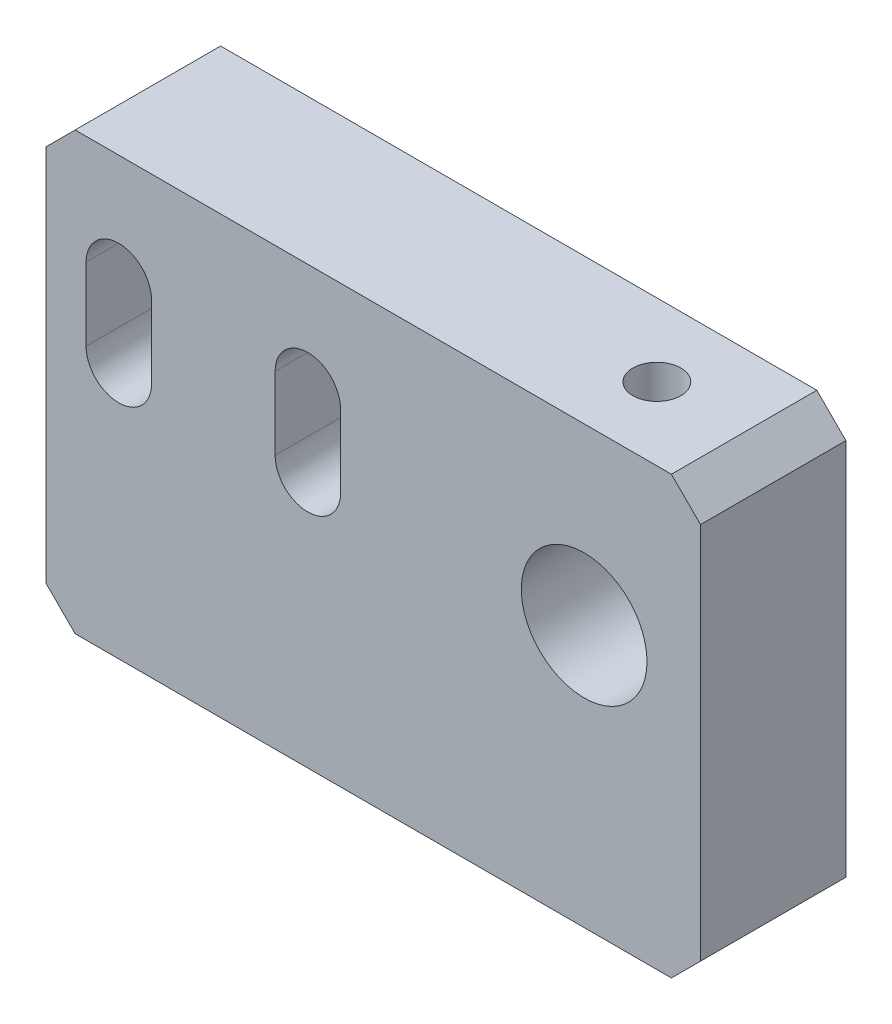
from build123d import *

# Parameters (mm, degrees)
SKETCH1_W             = 45
SKETCH1_H             = 30
SKETCH1_R             = 4.32205537
BOSS_EXTRUDE1_DEPTH   = 10
M4_TAPPED_HOLE1_D     = 3.3
M4_TAPPED_HOLE1_DEPTH = 10.1
M4_TAPPED_HOLE1_TIP   = 0.991420021
CHAMFER2_SIZE         = 2


with BuildPart() as part:
    # Sketch1 → Boss-Extrude1 (new body)
    with BuildSketch(Plane.XY):
        with Locations((7.992537313, -2.5)):
            Rectangle(SKETCH1_W, SKETCH1_H)
        with Locations((22.492537313, 0.5)):
            Circle(SKETCH1_R, mode=Mode.SUBTRACT)
        with BuildLine():
            Line((-7.257462687, 5), (-7.257462687, 0))
            ThreePointArc((-7.257462687, 0), (-9.507462687, -2.25), (-11.757462687, 0))
            Line((-11.757462687, 0), (-11.757462687, 5))
            ThreePointArc((-11.757462687, 5), (-9.507462687, 7.25), (-7.257462687, 5))
        make_face(mode=Mode.SUBTRACT)
        with BuildLine():
            Line((5.742537313, 5), (5.742537313, 0))
            ThreePointArc((5.742537313, 0), (3.492537313, -2.25), (1.242537313, 0))
            Line((1.242537313, 0), (1.242537313, 5))
            ThreePointArc((1.242537313, 5), (3.492537313, 7.25), (5.742537313, 5))
        make_face(mode=Mode.SUBTRACT)
    extrude(amount=BOSS_EXTRUDE1_DEPTH)

    # M4 Tapped Hole1
    with Locations(Plane(origin=(0, 12.5, 0), x_dir=(1, 0, 0), z_dir=(0, 1, 0))):
        with Locations((22.492537313, -5)):
            Hole(M4_TAPPED_HOLE1_D / 2, depth=M4_TAPPED_HOLE1_DEPTH)
            with Locations((0, 0, -(M4_TAPPED_HOLE1_DEPTH + M4_TAPPED_HOLE1_TIP / 2))):  # 118° drill point
                Cone(0, M4_TAPPED_HOLE1_D / 2, M4_TAPPED_HOLE1_TIP, mode=Mode.SUBTRACT)

    # Chamfer2
    chamfer2_edges = [part.edges().sort_by_distance(p)[0] for p in [
        (-14.507462687, 12.5, 5),
        (30.492537313, 12.5, 5),
        (30.492537313, -17.5, 5),
        (-14.507462687, -17.5, 5),
    ]]
    chamfer(chamfer2_edges, length=CHAMFER2_SIZE)


solid = part.part
